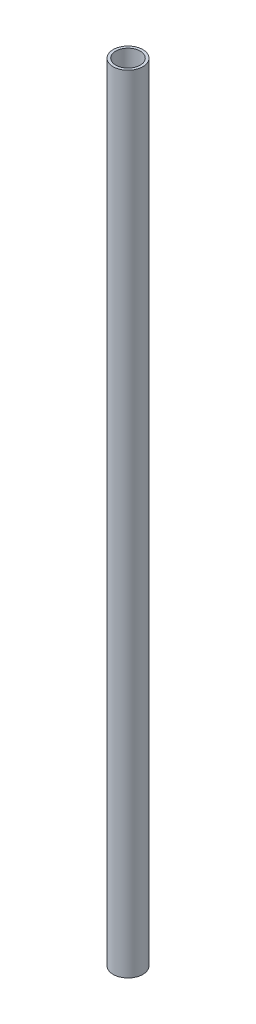
from build123d import *

# Parameters (mm, degrees)
SKETCH_1_R      = 17
SKETCH_1_R_2    = 14
EXTRUDE_1_DEPTH = 900


with BuildPart() as part:
    # Эскиз1 → Вытянуть-Тонкостенный1 (new body)
    with BuildSketch(Plane(origin=(0, 0, 0), x_dir=(1, 0, 0), z_dir=(0, 1, 0))):
        Circle(SKETCH_1_R)
        Circle(SKETCH_1_R_2, mode=Mode.SUBTRACT)
    extrude(amount=EXTRUDE_1_DEPTH)


solid = part.part
